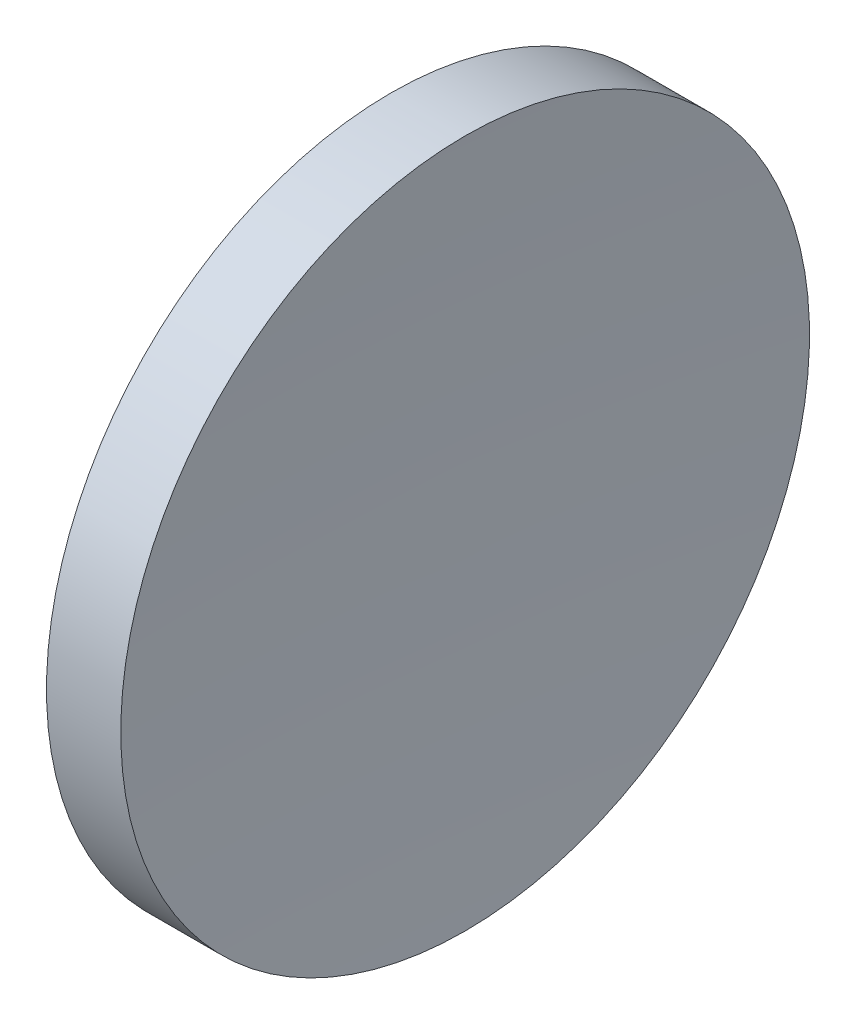
from build123d import *


with BuildPart() as part:
    # 草图1 → 旋转1 (revolve)
    with BuildSketch(Plane.XY, mode=Mode.PRIVATE) as revolve_1_sk:
        with BuildLine():
            Line((97.090443968, 52.178082298), (95.090443968, 52.178082298))
            ThreePointArc((95.090443968, 52.178082298), (95.001121219, 58.530866912), (94.720572201, 64.878082298))
            Line((94.720572201, 64.878082298), (96.090443968, 64.878082298))
            Line((96.090443968, 64.878082298), (97.460315736, 64.878082298))
            ThreePointArc((97.460315736, 64.878082298), (97.179766717, 58.530866912), (97.090443968, 52.178082298))
        make_face()
    revolve(revolve_1_sk.sketch.rotate(Axis((89.858656454, 52.178082298, 0), (1, 0, 0)), 180), axis=Axis((89.858656454, 52.178082298, 0), (1, 0, 0)))  # turned: the seam where the file's is


solid = part.part
